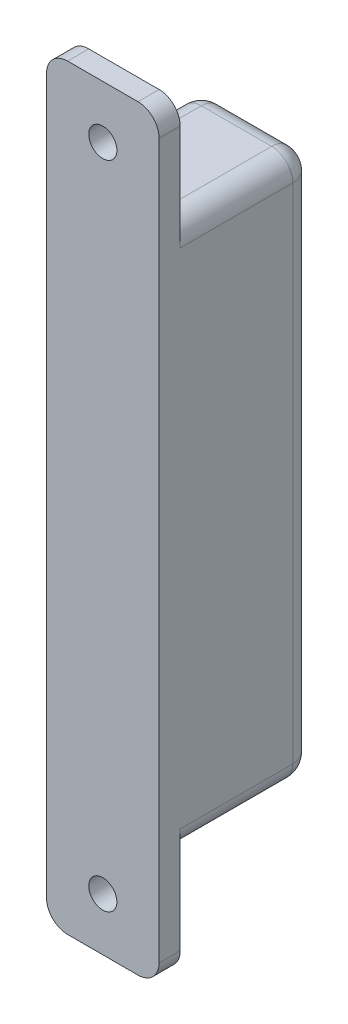
from build123d import *

# Parameters (mm, degrees)
SKETCH2_W           = 16
SKETCH2_H           = 77.5
BOSS_EXTRUDE1_DEPTH = 19
BOSS_EXTRUDE2_DEPTH = 3
SKETCH4_R           = 2
CUT_EXTRUDE1_DEPTH  = 23
FILLET1_R           = 3
FILLET2_R           = 3


with BuildPart() as part:
    # Sketch2 → Boss-Extrude1 (new body)
    with BuildSketch(Plane.XY):
        with Locations((8, 38.75)):
            Rectangle(SKETCH2_W, SKETCH2_H)
    extrude(amount=-BOSS_EXTRUDE1_DEPTH)

    # Sketch3 → Boss-Extrude2 (add)
    with BuildSketch(Plane.XY):
        Polygon((0, 77.5), (0, 92.5), (16, 92.5), (16, 0), (16, -15), (0, -15), align=None)
    extrude(amount=BOSS_EXTRUDE2_DEPTH)

    # Sketch4 → Cut-Extrude1 (cut, through all)
    with BuildSketch(Plane.XY.offset(3)):
        with Locations((8, 85)):
            Circle(SKETCH4_R)
        with Locations((8, -7.5)):
            Circle(SKETCH4_R)
    extrude(amount=-CUT_EXTRUDE1_DEPTH, mode=Mode.SUBTRACT)

    # Fillet1
    fillet1_edges = [part.edges().sort_by_distance(p)[0] for p in [
        (8, 77.5, -19),
        (0, 38.75, -19),
        (8, 0, -19),
        (16, 38.75, -19),
        (0, 0, -9.5),
        (0, 77.5, -9.5),
        (16, 77.5, -9.5),
        (16, 0, -9.5),
    ]]
    fillet(fillet1_edges, radius=FILLET1_R)

    # Fillet2
    fillet2_edges = [part.edges().sort_by_distance(p)[0] for p in [
        (0, -15, 1.5),
        (16, -15, 1.5),
        (16, 92.5, 1.5),
        (0, 92.5, 1.5),
    ]]
    fillet(fillet2_edges, radius=FILLET2_R)


solid = part.part
